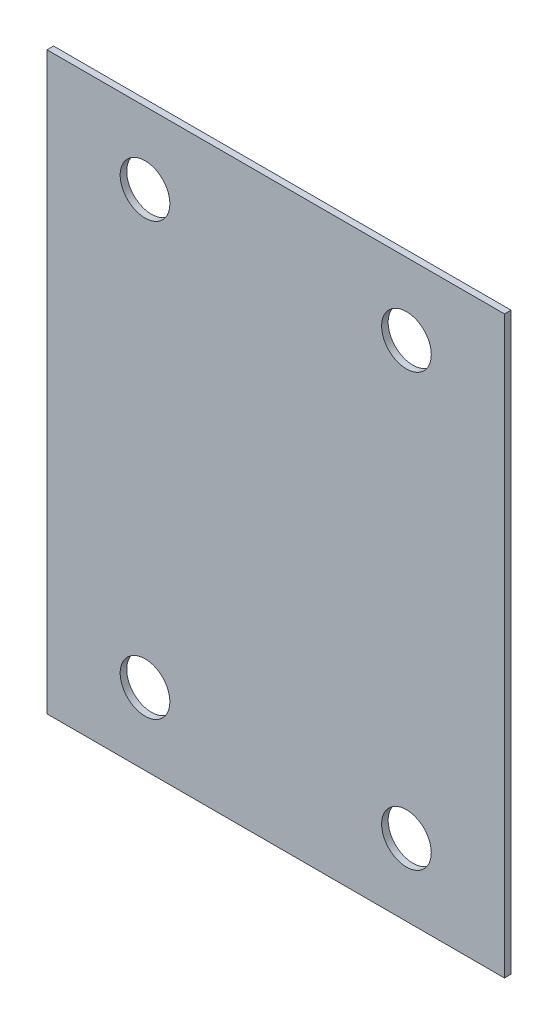
from build123d import *

# Parameters (mm, degrees)
SKETCH_1_W      = 350
SKETCH_1_H      = 440
SKETCH_1_R      = 19
EXTRUDE_1_DEPTH = 5


with BuildPart() as part:
    # Эскиз1 → Бобышка-Вытянуть1 (new body)
    with BuildSketch(Plane.XY):
        Rectangle(SKETCH_1_W, SKETCH_1_H)
        with Locations((-100, 165)):
            Circle(SKETCH_1_R, mode=Mode.SUBTRACT)
        with Locations((100, 165)):
            Circle(SKETCH_1_R, mode=Mode.SUBTRACT)
        with Locations((100, -165)):
            Circle(SKETCH_1_R, mode=Mode.SUBTRACT)
        with Locations((-100, -165)):
            Circle(SKETCH_1_R, mode=Mode.SUBTRACT)
    extrude(amount=EXTRUDE_1_DEPTH)


solid = part.part
